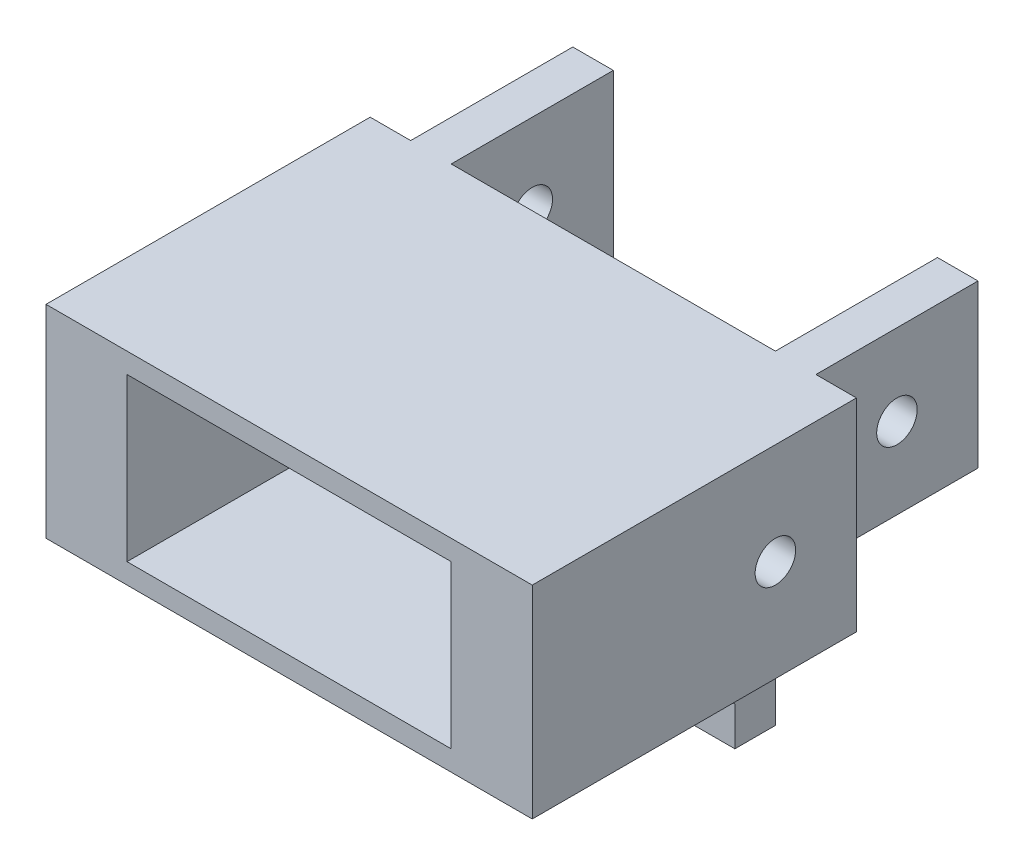
from build123d import *

# Parameters (mm, degrees)
ESQUISSE1_W                       = 40
ESQUISSE1_H                       = 15
BOSS_EXTRU_2_DEPTH                = 5
DIAM_TRE_DU_PER_AGE_5_0_5_1_D     = 5
DIAM_TRE_DU_PER_AGE_5_0_5_2_D     = 5
BOSS_EXTRU_3_DEPTH                = 40
ESQUISSE1_8_W                     = 5
ESQUISSE1_8_H                     = 20
BOSS_EXTRU_4_DEPTH                = 20
ESQUISSE1_9_W                     = 5
ESQUISSE1_9_H                     = 20
BOSS_EXTRU_5_DEPTH                = 20
DIAM_TRE_DU_PER_AGE_5_0_5_7_D     = 5
DIAM_TRE_DU_PER_AGE_5_0_5_7_DEPTH = 5
DIAM_TRE_DU_PER_AGE_5_0_5_8_D     = 5
DIAM_TRE_DU_PER_AGE_5_0_5_8_DEPTH = 5
ESQUISSE30_W                      = 40
ESQUISSE30_H                      = 20
ENL_V_MAT_EXTRU_1_DEPTH           = 35
DIAM_TRE_DU_PER_AGE_5_0_5_10_D    = 5
ESQUISSE37_W                      = 3
ESQUISSE37_H                      = 10
BOSS_EXTRU_6_DEPTH                = 10
ESQUISSE37_5_W                    = 3
ESQUISSE37_5_H                    = 10
ESQUISSE37_5_H_2                  = 10.219733904
BOSS_EXTRU_7_DEPTH                = 10
ENL_V_MAT_EXTRU_4_DEPTH           = 11
ENL_V_MAT_EXTRU_4_DEPTH_BACK      = 3
ENL_V_MAT_EXTRU_5_DEPTH           = 29.638558357
ENL_V_MAT_EXTRU_5_DEPTH_BACK      = 3
ENL_V_MAT_EXTRU_6_DEPTH           = 48
ENL_V_MAT_EXTRU_6_DEPTH_BACK      = 3


with BuildPart() as part:
    # Esquisse1 → Boss.-Extru.2 (new body)
    with BuildSketch(Plane.XY):
        with Locations((3.171437827, -12.450210199)):
            Rectangle(ESQUISSE1_W, ESQUISSE1_H)
    extrude(amount=BOSS_EXTRU_2_DEPTH)

    # Diamètre du perçage Ø5.0 (5)1 (through all)
    with Locations(Plane.XY.offset(5)):
        with Locations((13.171437827, -9.950210199)):
            Hole(DIAM_TRE_DU_PER_AGE_5_0_5_1_D / 2)

    # Diamètre du perçage Ø5.0 (5)2 (through all)
    with Locations(Plane.XY.offset(5)):
        with Locations((-6.828562173, -9.950210199)):
            Hole(DIAM_TRE_DU_PER_AGE_5_0_5_2_D / 2)

    # Esquisse1_6 → Boss.-Extru.3 (add)
    with BuildSketch(Plane.XY):
        Polygon((-16.828562173, 20.049789801), (23.171437827, 20.049789801), (28.171437827, 20.049789801), (33.171437827, 20.049789801), (33.171437827, -4.950210199), (23.171437827, -4.950210199), (-16.828562173, -4.950210199), (-26.828562173, -4.950210199), (-26.828562173, 20.049789801), (-21.828562173, 20.049789801), align=None)
    extrude(amount=BOSS_EXTRU_3_DEPTH)

    # Esquisse1_8 → Boss.-Extru.4 (add)
    with BuildSketch(Plane.XY):
        with Locations((25.671437827, 10.049789801)):
            Rectangle(ESQUISSE1_8_W, ESQUISSE1_8_H)
    extrude(amount=-BOSS_EXTRU_4_DEPTH)

    # Esquisse1_9 → Boss.-Extru.5 (add)
    with BuildSketch(Plane.XY):
        with Locations((-19.328562173, 10.049789801)):
            Rectangle(ESQUISSE1_9_W, ESQUISSE1_9_H)
    extrude(amount=-BOSS_EXTRU_5_DEPTH)

    # Diamètre du perçage Ø5.0 (5)7
    with Locations(Plane(origin=(28.171437827, 0, 0), x_dir=(0, 0, -1), z_dir=(1, 0, 0))):
        with Locations((10, 10.049789801)):
            Hole(DIAM_TRE_DU_PER_AGE_5_0_5_7_D / 2, depth=DIAM_TRE_DU_PER_AGE_5_0_5_7_DEPTH)

    # Diamètre du perçage Ø5.0 (5)8
    with Locations(Plane.ZY.offset(21.828562173)):
        with Locations((-10, 10.049789801)):
            Hole(DIAM_TRE_DU_PER_AGE_5_0_5_8_D / 2, depth=DIAM_TRE_DU_PER_AGE_5_0_5_8_DEPTH)

    # Esquisse30 → Enlèv. mat.-Extru.1 (cut)
    with BuildSketch(Plane.XY.offset(40)):
        with Locations((3.171437827, 7.549789801)):
            Rectangle(ESQUISSE30_W, ESQUISSE30_H)
    extrude(amount=-ENL_V_MAT_EXTRU_1_DEPTH, mode=Mode.SUBTRACT)

    # Diamètre du perçage Ø5.0 (5)10 (through all)
    with Locations(Plane(origin=(33.171437827, 0, 0), x_dir=(0, 0, -1), z_dir=(1, 0, 0))):
        with Locations((-10, 7.549789801)):
            Hole(DIAM_TRE_DU_PER_AGE_5_0_5_10_D / 2)

    # Esquisse37 → Boss.-Extru.6 (add)
    with BuildSketch(Plane.XY.offset(5)):
        with Locations((-15.328562173, -9.950210199)):
            Rectangle(ESQUISSE37_W, ESQUISSE37_H)
    extrude(amount=BOSS_EXTRU_6_DEPTH)

    # Esquisse37_5 → Boss.-Extru.7 (add)
    with BuildSketch(Plane.XY.offset(5)):
        with Locations((-15.328562173, -9.950210199)):
            Rectangle(ESQUISSE37_5_W, ESQUISSE37_5_H)
        with Locations((21.671437827, -10.060077151)):
            Rectangle(ESQUISSE37_5_W, ESQUISSE37_5_H_2)
        with Locations((3.309996184, -9.950210199)):
            Rectangle(ESQUISSE37_5_W, ESQUISSE37_5_H)
    extrude(amount=BOSS_EXTRU_7_DEPTH)

    # Esquisse38 → Enlèv. mat.-Extru.4 (cut, two sides)
    with BuildSketch(Plane.ZY.offset(16.828562173)) as enl_v_mat_extru_4_sk:
        Polygon((15, -14.950210199), (15, -4.950210199), (5, -14.950210199), align=None)
    extrude(amount=ENL_V_MAT_EXTRU_4_DEPTH, mode=Mode.SUBTRACT)
    extrude(enl_v_mat_extru_4_sk.sketch, amount=-ENL_V_MAT_EXTRU_4_DEPTH_BACK, mode=Mode.SUBTRACT)

    # Esquisse40 → Enlèv. mat.-Extru.5 (cut, two sides)
    with BuildSketch(Plane.ZY.offset(-1.809996184)) as enl_v_mat_extru_5_sk:
        Polygon((15, -14.950210199), (15, -4.950210199), (5, -14.950210199), align=None)
    extrude(amount=ENL_V_MAT_EXTRU_5_DEPTH, mode=Mode.SUBTRACT)
    extrude(enl_v_mat_extru_5_sk.sketch, amount=-ENL_V_MAT_EXTRU_5_DEPTH_BACK, mode=Mode.SUBTRACT)

    # Esquisse41 → Enlèv. mat.-Extru.6 (cut, two sides)
    with BuildSketch(Plane.ZY.offset(-20.171437827)) as enl_v_mat_extru_6_sk:
        Polygon((15, -15.169944103), (15, -4.950210199), (5, -15.169944103), align=None)
    extrude(amount=ENL_V_MAT_EXTRU_6_DEPTH, mode=Mode.SUBTRACT)
    extrude(enl_v_mat_extru_6_sk.sketch, amount=-ENL_V_MAT_EXTRU_6_DEPTH_BACK, mode=Mode.SUBTRACT)


solid = part.part
